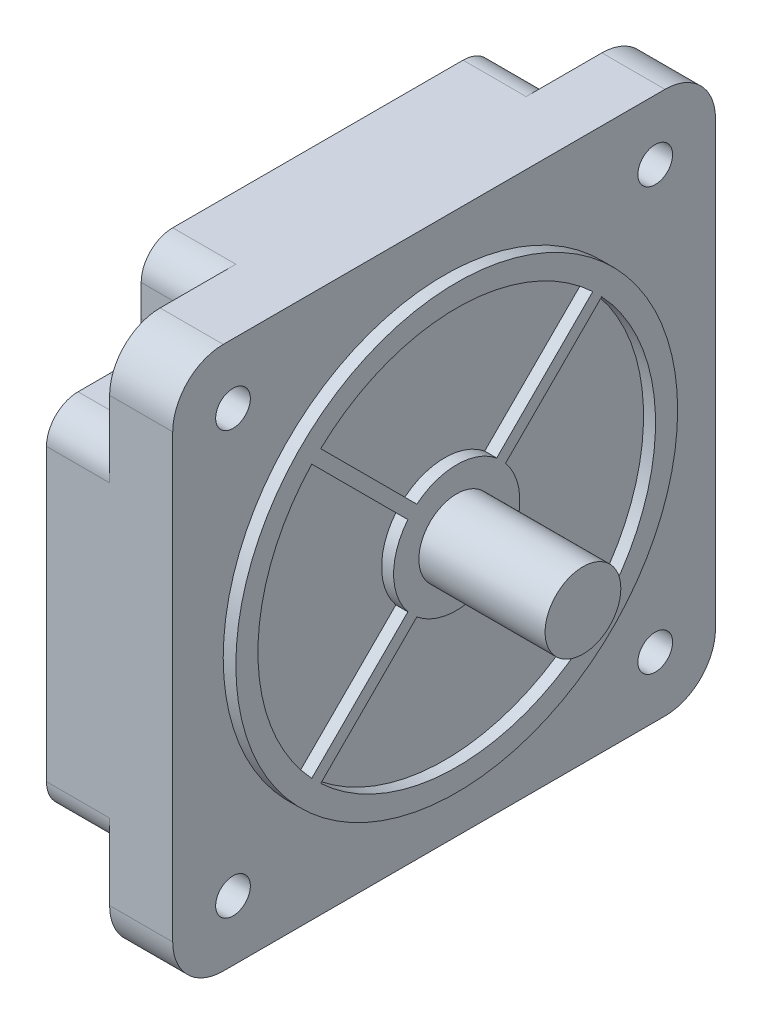
from build123d import *

# Parameters (mm, degrees)
BOSS_EXTRUDE1_DEPTH = 20
CUT_EXTRUDE1_DEPTH  = 10
FILLET1_R           = 5
SKETCH3_R           = 2.75
CUT_EXTRUDE2_DEPTH  = 10
SKETCH4_R           = 6
BOSS_EXTRUDE3_DEPTH = 22
SKETCH5_R           = 35
SKETCH5_R_2         = 31.5
SKETCH5_R_3         = 10
SKETCH5_R_4         = 6
BOSS_EXTRUDE4_DEPTH = 2
SKETCH6_R           = 31.5
SKETCH6_R_2         = 10
BOSS_EXTRUDE5_DEPTH = 0.1
BOSS_EXTRUDE6_DEPTH = 2


with BuildPart() as part:
    # Sketch1 → Boss-Extrude1 (new body)
    with BuildSketch(Plane(origin=(0, 0, 0), x_dir=(0, 0, -1), z_dir=(1, 0, 0))):
        with BuildLine():
            Line((8, 0), (78, 0))
            ThreePointArc((78, 0), (83.656854249, 2.343145751), (86, 8))
            Line((86, 8), (86, 78))
            ThreePointArc((86, 78), (83.656854249, 83.656854249), (78, 86))
            Line((78, 86), (8, 86))
            ThreePointArc((8, 86), (2.343145751, 83.656854249), (0, 78))
            Line((0, 78), (0, 8))
            ThreePointArc((0, 8), (2.343145751, 2.343145751), (8, 0))
        make_face()
    extrude(amount=BOSS_EXTRUDE1_DEPTH)

    # Sketch2 → Cut-Extrude1 (cut)
    with BuildSketch(Plane.ZY):
        with BuildLine():
            Line((-71, 76), (-71, 86))
            Line((-71, 86), (-78, 86))
            ThreePointArc((-78, 86), (-83.656854249, 83.656854249), (-86, 78))
            Line((-86, 78), (-86, 71))
            Line((-86, 71), (-76, 71))
            ThreePointArc((-76, 71), (-72.464466094, 72.464466094), (-71, 76))
        make_face()
        with BuildLine():
            Line((-8, 86), (-15, 86))
            Line((-15, 86), (-15, 76))
            ThreePointArc((-15, 76), (-13.535533906, 72.464466094), (-10, 71))
            Line((-10, 71), (0, 71))
            Line((0, 71), (0, 78))
            ThreePointArc((0, 78), (-2.343145751, 83.656854249), (-8, 86))
        make_face()
        with BuildLine():
            Line((0, 8), (0, 15))
            Line((0, 15), (-10, 15))
            ThreePointArc((-10, 15), (-13.535533906, 13.535533906), (-15, 10))
            Line((-15, 10), (-15, 0))
            Line((-15, 0), (-8, 0))
            ThreePointArc((-8, 0), (-2.343145751, 2.343145751), (0, 8))
        make_face()
        with BuildLine():
            Line((-76, 15), (-86, 15))
            Line((-86, 15), (-86, 8))
            ThreePointArc((-86, 8), (-83.656854249, 2.343145751), (-78, 0))
            Line((-78, 0), (-71, 0))
            Line((-71, 0), (-71, 10))
            ThreePointArc((-71, 10), (-72.464466094, 13.535533906), (-76, 15))
        make_face()
    extrude(amount=-CUT_EXTRUDE1_DEPTH, mode=Mode.SUBTRACT)

    # Fillet1
    fillet1_edges = [part.edges().sort_by_distance(p)[0] for p in [
        (5, 71, -86),
        (5, 86, -71),
        (5, 86, -15),
        (5, 71, 0),
        (5, 15, 0),
        (5, 0, -15),
        (5, 0, -71),
        (5, 15, -86),
    ]]
    fillet(fillet1_edges, radius=FILLET1_R)

    # Sketch3 → Cut-Extrude2 (cut)
    with BuildSketch(Plane(origin=(20, 0, 0), x_dir=(0, 0, -1), z_dir=(1, 0, 0))):
        with Locations((9.55, 76.45)):
            Circle(SKETCH3_R)
        with Locations((76.45, 76.45)):
            Circle(SKETCH3_R)
        with Locations((76.45, 9.55)):
            Circle(SKETCH3_R)
        with Locations((9.55, 9.55)):
            Circle(SKETCH3_R)
    extrude(amount=-CUT_EXTRUDE2_DEPTH, mode=Mode.SUBTRACT)

    # Sketch4 → Boss-Extrude3 (add)
    with BuildSketch(Plane(origin=(20, 0, 0), x_dir=(0, 0, -1), z_dir=(1, 0, 0))):
        with Locations((43, 43)):
            Circle(SKETCH4_R)
    extrude(amount=BOSS_EXTRUDE3_DEPTH)

    # Sketch5 → Boss-Extrude4 (add)
    with BuildSketch(Plane(origin=(20, 0, 0), x_dir=(0, 0, -1), z_dir=(1, 0, 0))):
        with Locations((43, 43)):
            Circle(SKETCH5_R)
        with Locations((43, 43)):
            Circle(SKETCH5_R_2, mode=Mode.SUBTRACT)
        with Locations((43, 43)):
            Circle(SKETCH5_R_3)
        with Locations((43, 43)):
            Circle(SKETCH5_R_4, mode=Mode.SUBTRACT)
    extrude(amount=BOSS_EXTRUDE4_DEPTH)

    # Sketch6 → Boss-Extrude5 (add)
    with BuildSketch(Plane(origin=(20, 0, 0), x_dir=(0, 0, -1), z_dir=(1, 0, 0))):
        with Locations((43, 43)):
            Circle(SKETCH6_R)
        with Locations((43, 43)):
            Circle(SKETCH6_R_2, mode=Mode.SUBTRACT)
    extrude(amount=BOSS_EXTRUDE5_DEPTH)

    # Sketch7 → Boss-Extrude6 (add)
    with BuildSketch(Plane(origin=(20, 0, 0), x_dir=(0, 0, -1), z_dir=(1, 0, 0))):
        Polygon((37.343145751, 50.071067812), (35.928932188, 48.656854249), (19.665476221, 64.920310217), (21.079689783, 66.334523779), align=None)
        Polygon((21.079689783, 19.665476221), (37.343145751, 35.928932188), (35.928932188, 37.343145751), (19.665476221, 21.079689783), align=None)
        Polygon((66.334523779, 21.079689783), (50.071067812, 37.343145751), (48.656854249, 35.928932188), (64.920310217, 19.665476221), align=None)
        Polygon((64.920310217, 66.334523779), (48.656854249, 50.071067812), (50.071067812, 48.656854249), (66.334523779, 64.920310217), align=None)
    extrude(amount=BOSS_EXTRUDE6_DEPTH)


solid = part.part
